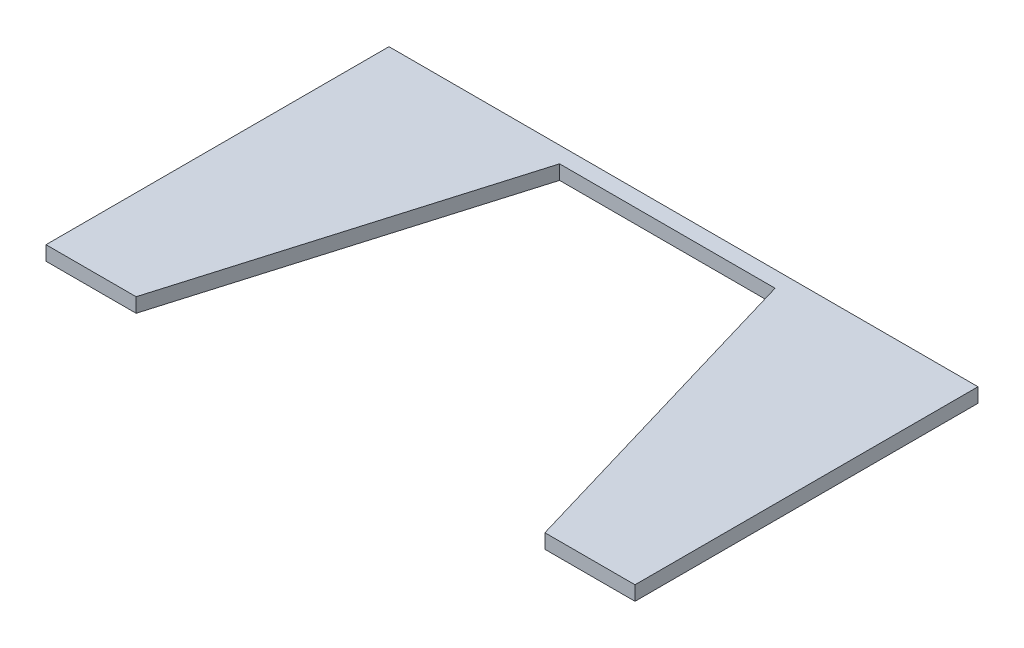
from build123d import *

# Parameters (mm, degrees)
BOSS_EXTRUDE1_DEPTH = 4


with BuildPart() as part:
    # Sketch1 → Boss-Extrude1 (new body)
    with BuildSketch(Plane(origin=(0, 0, 0), x_dir=(1, 0, 0), z_dir=(0, 1, 0))):
        Polygon((30, 1), (56.908602151, -90), (82, -90), (82, 5.5), (-82, 5.5), (-82, -90), (-56.908602151, -90), (-30, 1), align=None)
    extrude(amount=BOSS_EXTRUDE1_DEPTH)


solid = part.part
